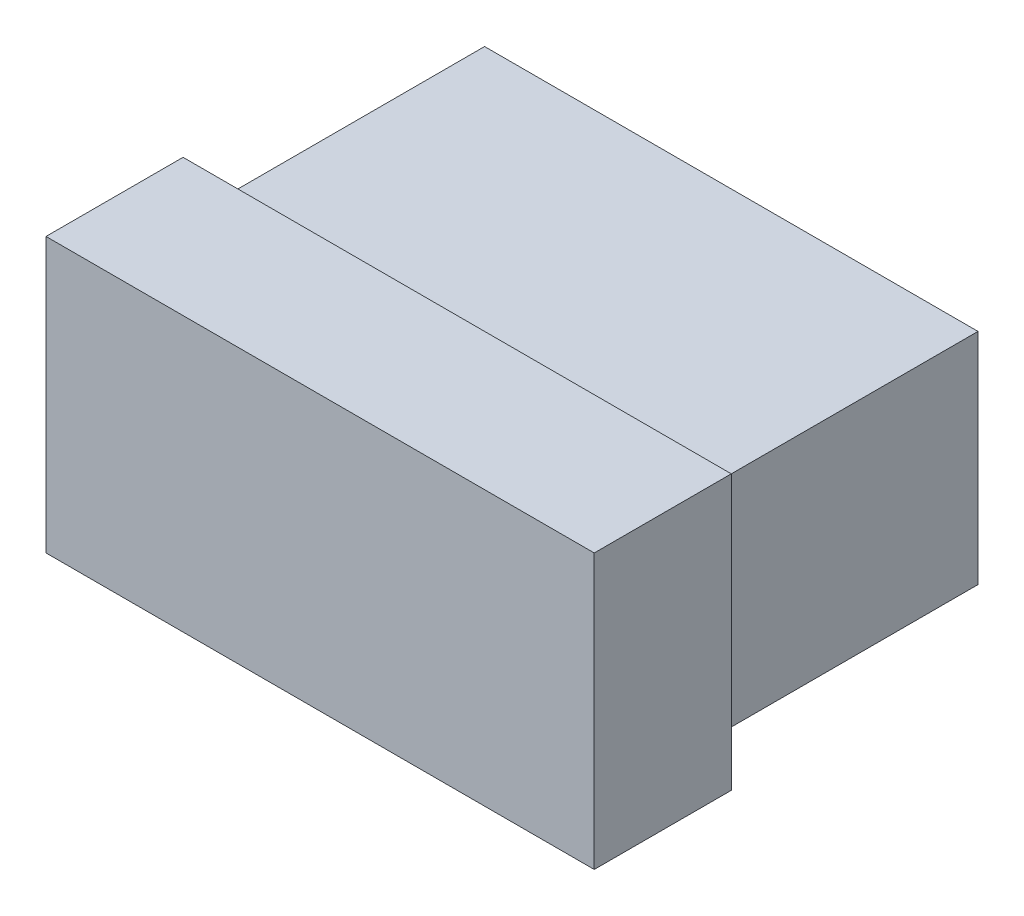
from build123d import *

# Parameters (mm, degrees)
SKETCH1_W           = 22.86
SKETCH1_H           = 10.16
BOSS_EXTRUDE1_DEPTH = 12.7
SKETCH2_W           = 25.4
SKETCH2_H           = 12.7
BOSS_EXTRUDE2_DEPTH = 6.35


with BuildPart() as part:
    # Sketch1 → Boss-Extrude1 (new body)
    with BuildSketch(Plane.XY):
        Rectangle(SKETCH1_W, SKETCH1_H)
    extrude(amount=-BOSS_EXTRUDE1_DEPTH)

    # Sketch2 → Boss-Extrude2 (add)
    with BuildSketch(Plane.XY):
        Rectangle(SKETCH2_W, SKETCH2_H)
    extrude(amount=BOSS_EXTRUDE2_DEPTH)


solid = part.part
